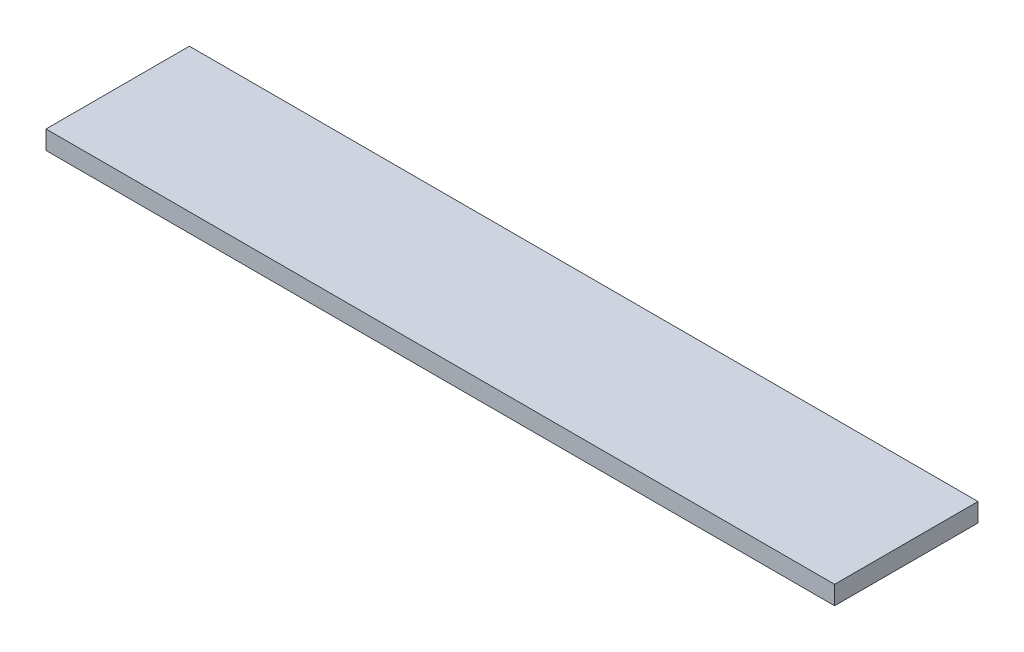
from build123d import *

# Parameters (mm, degrees)
SKETCH1_W           = 69.85
SKETCH1_H           = 12.7
BOSS_EXTRUDE1_DEPTH = 1.651


with BuildPart() as part:
    # Sketch1 → Boss-Extrude1 (new body)
    with BuildSketch(Plane(origin=(0, 0, 0), x_dir=(1, 0, 0), z_dir=(0, 1, 0))):
        Rectangle(SKETCH1_W, SKETCH1_H)
    extrude(amount=BOSS_EXTRUDE1_DEPTH)


solid = part.part
